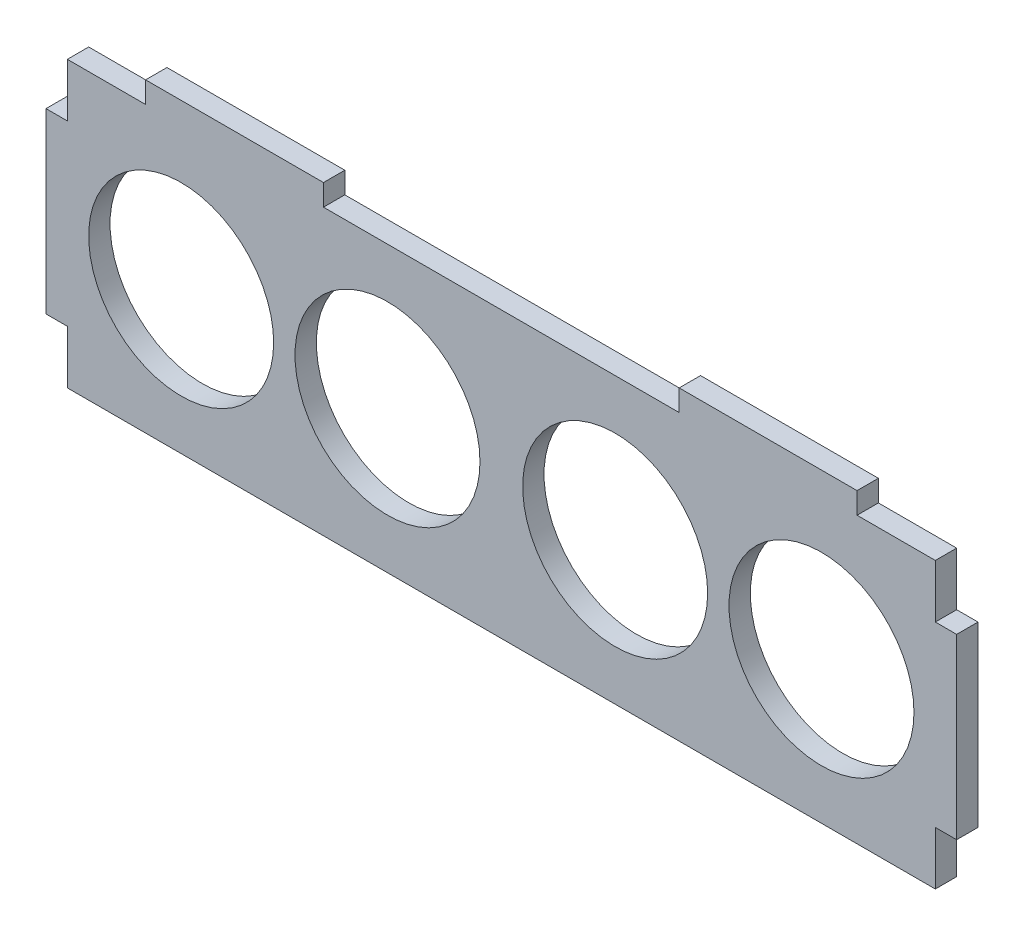
from build123d import *

# Parameters (mm, degrees)
SKETCH1_R           = 13
BOSS_EXTRUDE1_DEPTH = 3


with BuildPart() as part:
    # Sketch1 → Boss-Extrude1 (new body)
    with BuildSketch(Plane.XY):
        Polygon((-61, -12.5), (-61, -20), (61, -20), (61, -12.5), (64, -12.5), (64, 12.5), (61, 12.5), (61, 20), (50, 20), (50, 23), (25, 23), (25, 20), (-25, 20), (-25, 23), (-50, 23), (-50, 20), (-61, 20), (-61, 12.5), (-64, 12.5), (-64, -12.5), align=None)
        with Locations((-45, 0)):
            Circle(SKETCH1_R, mode=Mode.SUBTRACT)
        with Locations((-16, 0)):
            Circle(SKETCH1_R, mode=Mode.SUBTRACT)
        with Locations((16, 0)):
            Circle(SKETCH1_R, mode=Mode.SUBTRACT)
        with Locations((45, 0)):
            Circle(SKETCH1_R, mode=Mode.SUBTRACT)
    extrude(amount=BOSS_EXTRUDE1_DEPTH)


solid = part.part
